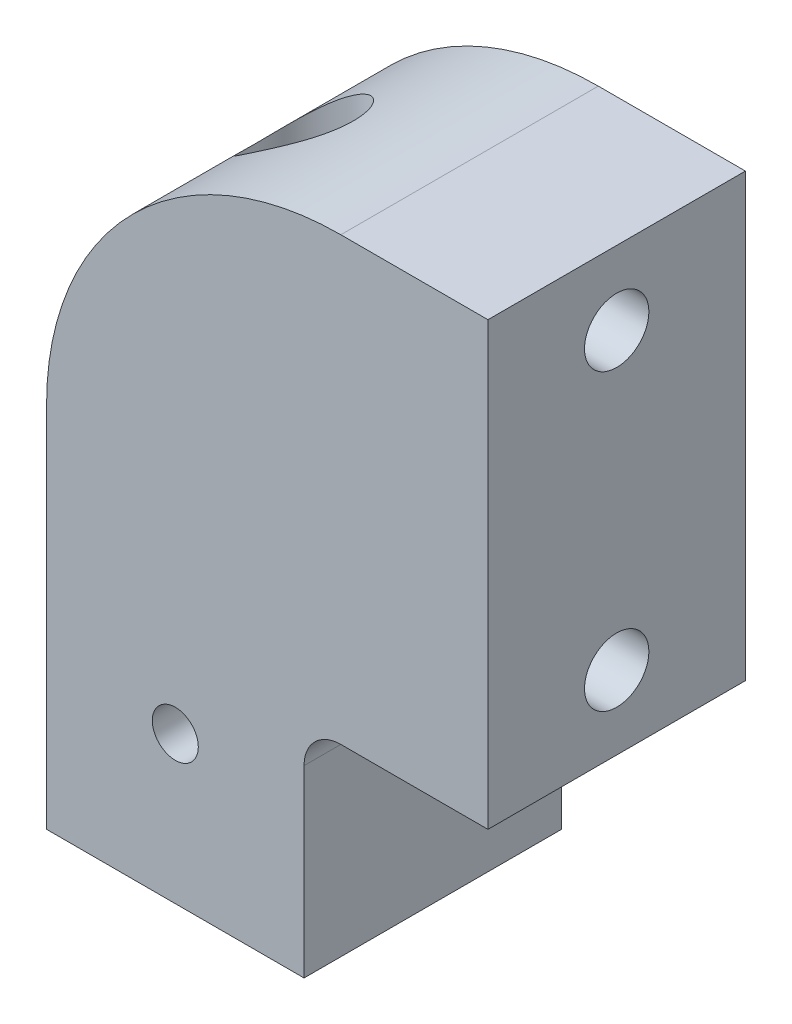
from build123d import *

# Parameters (mm, degrees)
BOSS_EXTRUDE1_DEPTH                 = 22.225
FILLET1_R                           = 3.175
FILLET2_R                           = 25.4
SKETCH3_R                           = 7.14375
CUT_EXTRUDE1_DEPTH                  = 9.525
SKETCH4_R                           = 4.25
CUT_EXTRUDE2_DEPTH                  = 58.15
F_7_32_0_21875_DIAMETER_HOLE1_D     = 5.55625
F_7_32_0_21875_DIAMETER_HOLE1_DEPTH = 7.9375
F_7_32_0_21875_DIAMETER_HOLE1_TIP   = 1.669265907
SKETCH9_R                           = 1.984375
CUT_EXTRUDE3_DEPTH                  = 23.2250001
SKETCH10_R                          = 1.984375
CUT_EXTRUDE4_DEPTH                  = 23.2250001


with BuildPart() as part:
    # Sketch1 → Boss-Extrude1 (new body)
    with BuildSketch(Plane.XY):
        Polygon((0, 0), (0, 57.15), (38.1, 57.15), (38.1, 19.05), (22.225, 19.05), (22.225, 0), align=None)
    extrude(amount=BOSS_EXTRUDE1_DEPTH)

    # Fillet1
    fillet1_edges = [part.edges().sort_by_distance(p)[0] for p in [
        (22.225, 19.05, 11.1125),
    ]]
    fillet(fillet1_edges, radius=FILLET1_R)

    # Fillet2
    fillet2_edges = [part.edges().sort_by_distance(p)[0] for p in [
        (0, 57.15, 11.1125),
    ]]
    fillet(fillet2_edges, radius=FILLET2_R)

    # Sketch3 → Cut-Extrude1 (cut)
    with BuildSketch(Plane.XZ):
        with Locations((11.1125, 11.1125)):
            Circle(SKETCH3_R)
    extrude(amount=-CUT_EXTRUDE1_DEPTH, mode=Mode.SUBTRACT)

    # Sketch4 → Cut-Extrude2 (cut, through all)
    with BuildSketch(Plane.XZ):
        with Locations((11.1125, 11.1125)):
            Circle(SKETCH4_R)
    extrude(amount=-CUT_EXTRUDE2_DEPTH, mode=Mode.SUBTRACT)

    # 7/32 (0.21875) Diameter Hole1
    with Locations(Plane(origin=(38.1, 0, 0), x_dir=(0, 0, -1), z_dir=(1, 0, 0))):
        with Locations((-11.1125, 50.8), (-11.1125, 25.4)):
            Hole(F_7_32_0_21875_DIAMETER_HOLE1_D / 2, depth=F_7_32_0_21875_DIAMETER_HOLE1_DEPTH)
            with Locations((0, 0, -(F_7_32_0_21875_DIAMETER_HOLE1_DEPTH + F_7_32_0_21875_DIAMETER_HOLE1_TIP / 2))):  # 118° drill point
                Cone(0, F_7_32_0_21875_DIAMETER_HOLE1_D / 2, F_7_32_0_21875_DIAMETER_HOLE1_TIP, mode=Mode.SUBTRACT)

    # Sketch9 → Cut-Extrude3 (cut, through all)
    with BuildSketch(Plane(origin=(22.225, 0, 0), x_dir=(0, 0, -1), z_dir=(1, 0, 0))):
        with Locations((-11.1125, 12.7)):
            Circle(SKETCH9_R)
    extrude(amount=-CUT_EXTRUDE3_DEPTH, mode=Mode.SUBTRACT)

    # Sketch10 → Cut-Extrude4 (cut, through all)
    with BuildSketch(Plane.XY.offset(22.225)):
        with Locations((11.1125, 12.7)):
            Circle(SKETCH10_R)
    extrude(amount=-CUT_EXTRUDE4_DEPTH, mode=Mode.SUBTRACT)


solid = part.part
